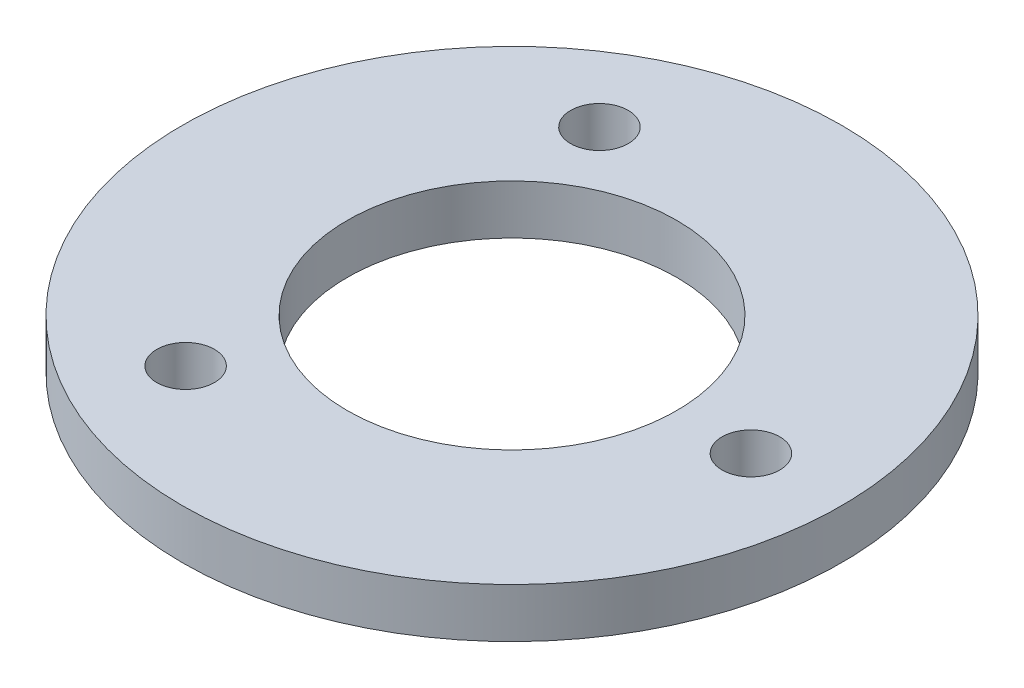
from build123d import *

# Parameters (mm, degrees)
SZKIC1_R                    = 20
SZKIC1_R_2                  = 10
SZKIC1_R_3                  = 1.75
DODANIE_WYCI_GNI_CIE1_DEPTH = 3


with BuildPart() as part:
    # Szkic1 → Dodanie-wyciągnięcie1 (new body)
    with BuildSketch(Plane(origin=(0, 0, 0), x_dir=(1, 0, 0), z_dir=(0, 1, 0))):
        Circle(SZKIC1_R)
        Circle(SZKIC1_R_2, mode=Mode.SUBTRACT)
        with Locations((14.5, 0)):
            Circle(SZKIC1_R_3, mode=Mode.SUBTRACT)
        with Locations((-7.25, -12.557368355)):
            Circle(SZKIC1_R_3, mode=Mode.SUBTRACT)
        with Locations((-7.25, 12.557368355)):
            Circle(SZKIC1_R_3, mode=Mode.SUBTRACT)
    extrude(amount=DODANIE_WYCI_GNI_CIE1_DEPTH)


solid = part.part
